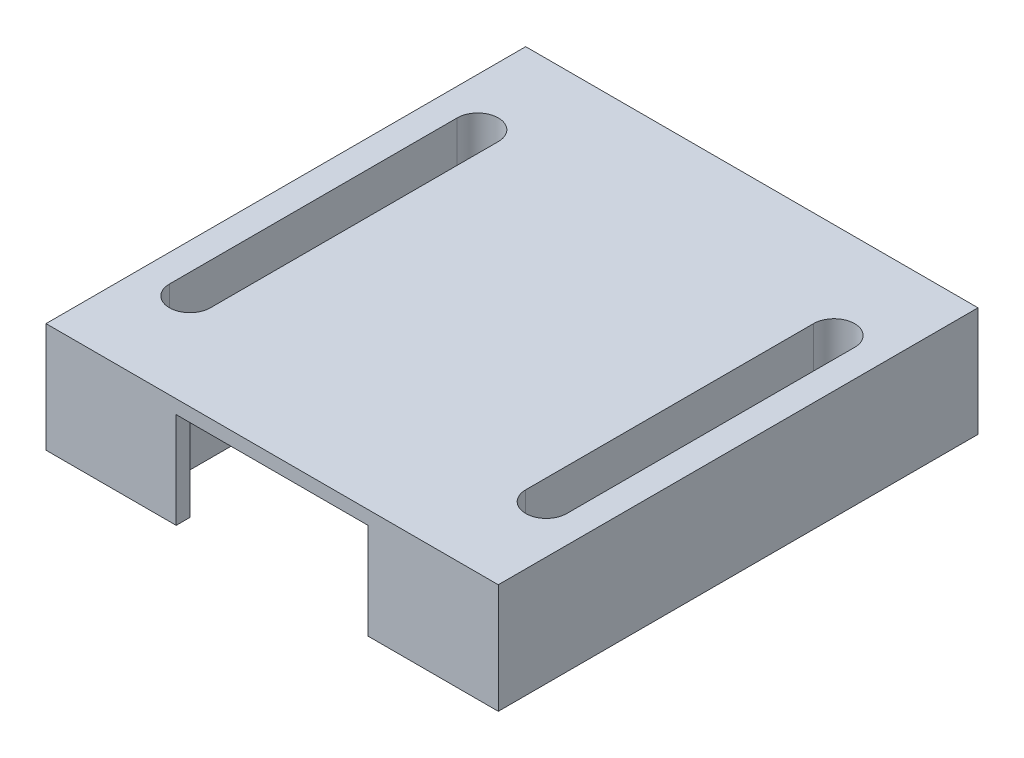
from build123d import *

# Parameters (mm, degrees)
SKETCH1_W           = 33
SKETCH1_H           = 35
BOSS_EXTRUDE1_DEPTH = 8
SKETCH2_W           = 20
SKETCH2_H           = 33
CUT_EXTRUDE1_DEPTH  = 7
CUT_EXTRUDE3_DEPTH  = 9
SKETCH3_W           = 14
SKETCH3_H           = 7
CUT_EXTRUDE4_DEPTH  = 7


with BuildPart() as part:
    # Sketch1 → Boss-Extrude1 (new body)
    with BuildSketch(Plane(origin=(0, 0, 0), x_dir=(1, 0, 0), z_dir=(0, 1, 0))):
        Rectangle(SKETCH1_W, SKETCH1_H)
    extrude(amount=BOSS_EXTRUDE1_DEPTH)

    # Sketch2 → Cut-Extrude1 (cut)
    with BuildSketch(Plane.XZ):
        Rectangle(SKETCH2_W, SKETCH2_H)
    extrude(amount=-CUT_EXTRUDE1_DEPTH, mode=Mode.SUBTRACT)

    # Sketch4 → Cut-Extrude3 (cut, through all)
    with BuildSketch(Plane(origin=(0, 8, 0), x_dir=(1, 0, 0), z_dir=(0, 1, 0))):
        with BuildLine():
            Line((14.5, 10.5), (14.5, -10.5))
            ThreePointArc((14.5, -10.5), (13, -12), (11.5, -10.5))
            Line((11.5, -10.5), (11.5, 10.5))
            ThreePointArc((11.5, 10.5), (13, 12), (14.5, 10.5))
        make_face()
        with BuildLine():
            Line((-14.5, 10.5), (-14.5, -10.5))
            ThreePointArc((-14.5, -10.5), (-13, -12), (-11.5, -10.5))
            Line((-11.5, -10.5), (-11.5, 10.5))
            ThreePointArc((-11.5, 10.5), (-13, 12), (-14.5, 10.5))
        make_face()
    extrude(amount=-CUT_EXTRUDE3_DEPTH, mode=Mode.SUBTRACT)

    # Sketch3 → Cut-Extrude4 (cut)
    with BuildSketch(Plane.XY.offset(17.5)):
        with Locations((0, 3.5)):
            Rectangle(SKETCH3_W, SKETCH3_H)
    extrude(amount=-CUT_EXTRUDE4_DEPTH, mode=Mode.SUBTRACT)


solid = part.part
